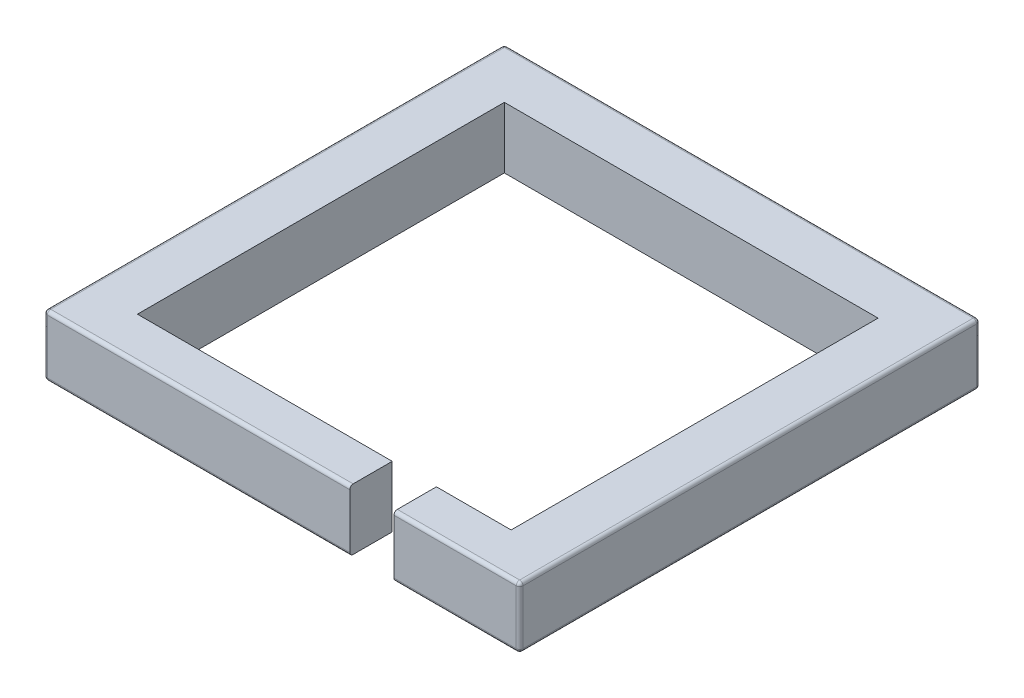
from build123d import *

# Parameters (mm, degrees)
SKETCH2_W           = 889
SKETCH2_H           = 860.425
SKETCH2_W_2         = 698.5
SKETCH2_H_2         = 685.8
BOSS_EXTRUDE1_DEPTH = 114.3
SKETCH3_W           = 82.55
SKETCH3_H           = 79.375
CUT_EXTRUDE1_DEPTH  = 115.3
FILLET1_R           = 6.35


with BuildPart() as part:
    # Sketch2 → Boss-Extrude1 (new body)
    with BuildSketch(Plane(origin=(0, 0, 0), x_dir=(1, 0, 0), z_dir=(0, 1, 0))):
        with Locations((0, 7.9375)):
            Rectangle(SKETCH2_W, SKETCH2_H)
        Rectangle(SKETCH2_W_2, SKETCH2_H_2, mode=Mode.SUBTRACT)
    extrude(amount=BOSS_EXTRUDE1_DEPTH)

    # Sketch3 → Cut-Extrude1 (cut, through all)
    with BuildSketch(Plane(origin=(0, 114.3, 0), x_dir=(1, 0, 0), z_dir=(0, 1, 0))):
        with Locations((168.275, -382.5875)):
            Rectangle(SKETCH3_W, SKETCH3_H)
    extrude(amount=-CUT_EXTRUDE1_DEPTH, mode=Mode.SUBTRACT)

    # Fillet1
    fillet1_edges = [part.edges().sort_by_distance(p)[0] for p in [
        (444.5, 114.3, -7.9375),
        (0, 114.3, -438.15),
        (327.025, 0, 422.275),
        (327.025, 114.3, 422.275),
        (-444.5, 114.3, -7.9375),
        (0, 0, -438.15),
        (444.5, 0, -7.9375),
        (-158.75, 0, 422.275),
        (-444.5, 0, -7.9375),
        (-444.5, 57.15, -438.15),
        (444.5, 57.15, -438.15),
        (444.5, 57.15, 422.275),
        (-444.5, 57.15, 422.275),
        (-158.75, 114.3, 422.275),
    ]]
    fillet(fillet1_edges, radius=FILLET1_R)


solid = part.part
